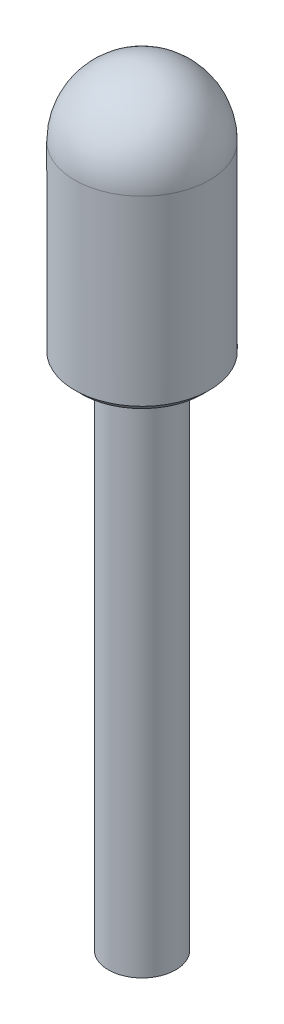
from build123d import *

# Parameters (mm, degrees)
CHAMFER1_SIZE = 0.1


with BuildPart() as part:
    # Sketch1 → Revolve1 (revolve)
    with BuildSketch(Plane.XY):
        with BuildLine():
            Line((0, 0), (0.5, 0))
            Line((0.5, 0), (0.5, 7.6))
            Line((0.5, 7.6), (1, 7.6))
            Line((1, 7.6), (1, 10.4))
            ThreePointArc((1, 10.4), (0.707106781, 11.107106781), (0, 11.4))
            Line((0, 11.4), (0, 0))
        make_face()
    revolve(axis=Axis((0, 0, 0), (0, 1, 0)))

    # Chamfer1
    chamfer1_edges = [part.edges().sort_by_distance(p)[0] for p in [
        (-1, 7.6, 0),
    ]]
    chamfer(chamfer1_edges, length=CHAMFER1_SIZE)


solid = part.part
